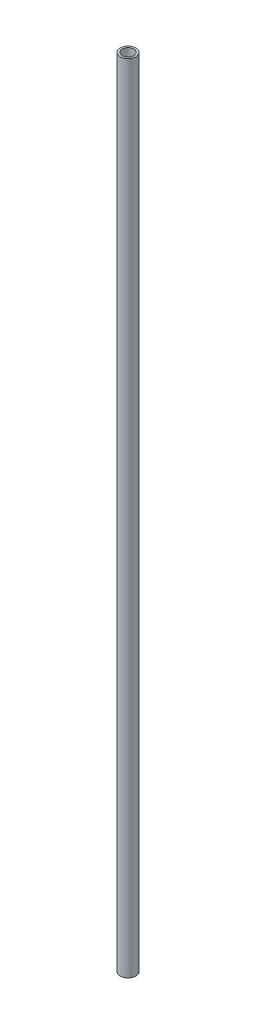
from build123d import *

# Parameters (mm, degrees)
SKETCH1_R           = 19.5
SKETCH1_R_2         = 14.5
BOSS_EXTRUDE1_DEPTH = 2000


with BuildPart() as part:
    # Sketch1 → Boss-Extrude1 (new body)
    with BuildSketch(Plane(origin=(0, 0, 0), x_dir=(1, 0, 0), z_dir=(0, 1, 0))):
        Circle(SKETCH1_R)
        Circle(SKETCH1_R_2, mode=Mode.SUBTRACT)
    extrude(amount=BOSS_EXTRUDE1_DEPTH)


solid = part.part
